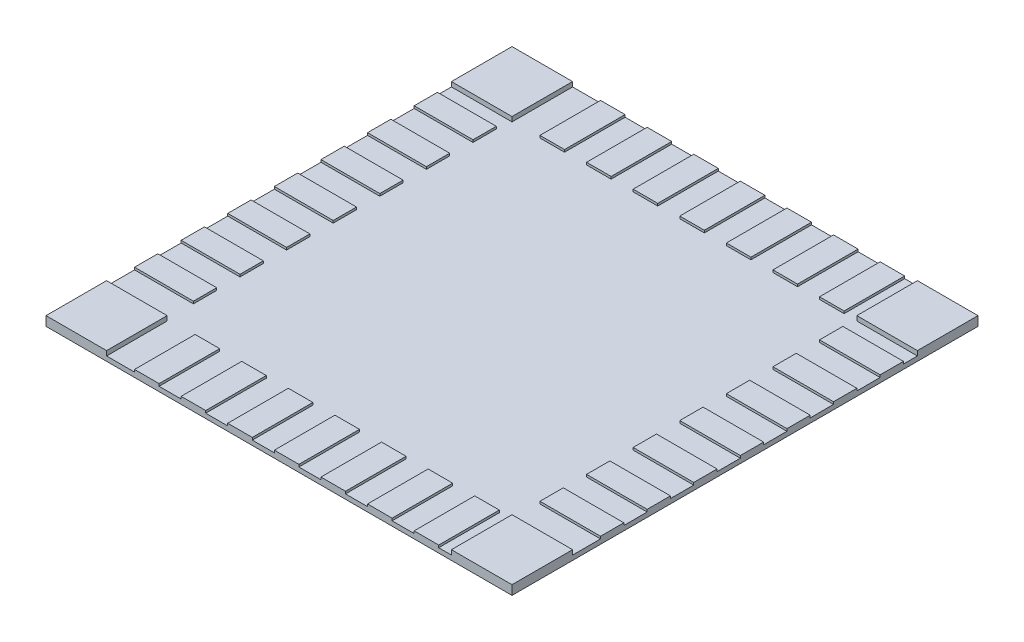
from build123d import *

# Parameters (mm, degrees)
ESBO_O1_W                = 1
ESBO_O1_H                = 1
RESSALTO_EXTRUS_O1_DEPTH = 0.01
ESBO_O3_W                = 0.052728247
ESBO_O3_H                = 0.13
ESBO_O3_W_2              = 0.13
ESBO_O3_H_2              = 0.05
ESBO_O3_W_3              = 0.126315558
RESSALTO_EXTRUS_O2_DEPTH = 0.005
ESBO_O2_W                = 0.13
ESBO_O2_H                = 0.13
RESSALTO_EXTRUS_O4_DEPTH = 0.02


with BuildPart() as part:
    # Esboço1 → Ressalto-extrusão1 (new body)
    with BuildSketch(Plane(origin=(0, 0, 0), x_dir=(1, 0, 0), z_dir=(0, 1, 0))):
        Rectangle(ESBO_O1_W, ESBO_O1_H)
    extrude(amount=RESSALTO_EXTRUS_O1_DEPTH)

    # Esboço3 → Ressalto-extrusão2 (add)
    with BuildSketch(Plane(origin=(0, 0.01, 0), x_dir=(1, 0, 0), z_dir=(0, 1, 0))):
        with Locations((-0.283635876, -0.435)):
            Rectangle(ESBO_O3_W, ESBO_O3_H)
        with Locations((0.435, -0.185)):
            Rectangle(ESBO_O3_W_2, ESBO_O3_H_2)
        with Locations((-0.183635877, -0.435)):
            Rectangle(ESBO_O3_W, ESBO_O3_H)
        with Locations((-0.083635876, -0.435)):
            Rectangle(ESBO_O3_W, ESBO_O3_H)
        with Locations((0.016364124, -0.435)):
            Rectangle(ESBO_O3_W, ESBO_O3_H)
        with Locations((0.116364123, -0.435)):
            Rectangle(ESBO_O3_W, ESBO_O3_H)
        with Locations((0.216364124, -0.435)):
            Rectangle(ESBO_O3_W, ESBO_O3_H)
        with Locations((0.316364124, -0.435)):
            Rectangle(ESBO_O3_W, ESBO_O3_H)
        with Locations((0.435, -0.285)):
            Rectangle(ESBO_O3_W_2, ESBO_O3_H_2)
        with Locations((0.435, -0.085)):
            Rectangle(ESBO_O3_W_2, ESBO_O3_H_2)
        with Locations((0.435, 0.015)):
            Rectangle(ESBO_O3_W_2, ESBO_O3_H_2)
        with Locations((0.435, 0.115)):
            Rectangle(ESBO_O3_W_2, ESBO_O3_H_2)
        with Locations((0.435, 0.215)):
            Rectangle(ESBO_O3_W_2, ESBO_O3_H_2)
        with Locations((0.435, 0.315)):
            Rectangle(ESBO_O3_W_2, ESBO_O3_H_2)
        with Locations((0.316364124, 0.435)):
            Rectangle(ESBO_O3_W, ESBO_O3_H)
        with Locations((0.216364124, 0.435)):
            Rectangle(ESBO_O3_W, ESBO_O3_H)
        with Locations((0.116364123, 0.435)):
            Rectangle(ESBO_O3_W, ESBO_O3_H)
        with Locations((0.016364124, 0.435)):
            Rectangle(ESBO_O3_W, ESBO_O3_H)
        with Locations((-0.083635876, 0.435)):
            Rectangle(ESBO_O3_W, ESBO_O3_H)
        with Locations((-0.183635877, 0.435)):
            Rectangle(ESBO_O3_W, ESBO_O3_H)
        with Locations((-0.283635876, 0.435)):
            Rectangle(ESBO_O3_W, ESBO_O3_H)
        with Locations((-0.436842221, 0.315)):
            Rectangle(ESBO_O3_W_3, ESBO_O3_H_2)
        with Locations((-0.436842221, 0.215)):
            Rectangle(ESBO_O3_W_3, ESBO_O3_H_2)
        with Locations((-0.436842221, 0.115)):
            Rectangle(ESBO_O3_W_3, ESBO_O3_H_2)
        with Locations((-0.436842221, 0.015)):
            Rectangle(ESBO_O3_W_3, ESBO_O3_H_2)
        with Locations((-0.436842221, -0.085)):
            Rectangle(ESBO_O3_W_3, ESBO_O3_H_2)
        with Locations((-0.436842221, -0.185)):
            Rectangle(ESBO_O3_W_3, ESBO_O3_H_2)
        with Locations((-0.436842221, -0.285)):
            Rectangle(ESBO_O3_W_3, ESBO_O3_H_2)
    extrude(amount=RESSALTO_EXTRUS_O2_DEPTH)

    # Esboço2 → Ressalto-extrusão4 (add)
    with BuildSketch(Plane(origin=(0, 0, 0), x_dir=(1, 0, 0), z_dir=(0, 1, 0))):
        with Locations((-0.435, -0.435)):
            Rectangle(ESBO_O2_W, ESBO_O2_H)
        with Locations((0.435, 0.435)):
            Rectangle(ESBO_O2_W, ESBO_O2_H)
        with Locations((0.435, -0.435)):
            Rectangle(ESBO_O2_W, ESBO_O2_H)
        with Locations((-0.435, 0.435)):
            Rectangle(ESBO_O2_W, ESBO_O2_H)
    extrude(amount=RESSALTO_EXTRUS_O4_DEPTH)


solid = part.part
